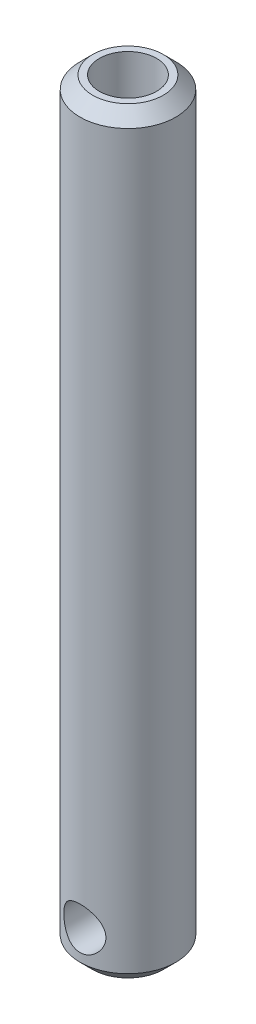
from build123d import *

# Parameters (mm, degrees)
SKETCH1_R             = 5.7
BOSS_EXTRUDE1_DEPTH   = 90
M8_TAPPED_HOLE1_D     = 6.8
M8_TAPPED_HOLE1_DEPTH = 35
M8_TAPPED_HOLE1_TIP   = 1.962990915
CHAMFER2_SIZE         = 1.5
SKETCH4_R             = 2.5
CUT_EXTRUDE1_DEPTH    = 10


with BuildPart() as part:
    # Sketch1 → Boss-Extrude1 (new body)
    with BuildSketch(Plane(origin=(0, 0, 0), x_dir=(1, 0, 0), z_dir=(0, 1, 0))):
        Circle(SKETCH1_R)
    extrude(amount=BOSS_EXTRUDE1_DEPTH)

    # M8 Tapped Hole1
    with Locations(Plane(origin=(0, 90, 0), x_dir=(1, 0, 0), z_dir=(0, 1, 0))):
        with Locations((0, 0)):
            Hole(M8_TAPPED_HOLE1_D / 2, depth=M8_TAPPED_HOLE1_DEPTH)
            with Locations((0, 0, -(M8_TAPPED_HOLE1_DEPTH + M8_TAPPED_HOLE1_TIP / 2))):  # 120° drill point
                Cone(0, M8_TAPPED_HOLE1_D / 2, M8_TAPPED_HOLE1_TIP, mode=Mode.SUBTRACT)

    # Chamfer2
    chamfer2_edges = [part.edges().sort_by_distance(p)[0] for p in [
        (-5.7, 0, 0),
        (-5.7, 90, 0),
    ]]
    chamfer(chamfer2_edges, length=CHAMFER2_SIZE)

    # Sketch4 → Cut-Extrude1 (cut, symmetric)
    with BuildSketch(Plane.XY):
        with Locations((0, 5)):
            Circle(SKETCH4_R)
    extrude(amount=CUT_EXTRUDE1_DEPTH, both=True, mode=Mode.SUBTRACT)


solid = part.part
